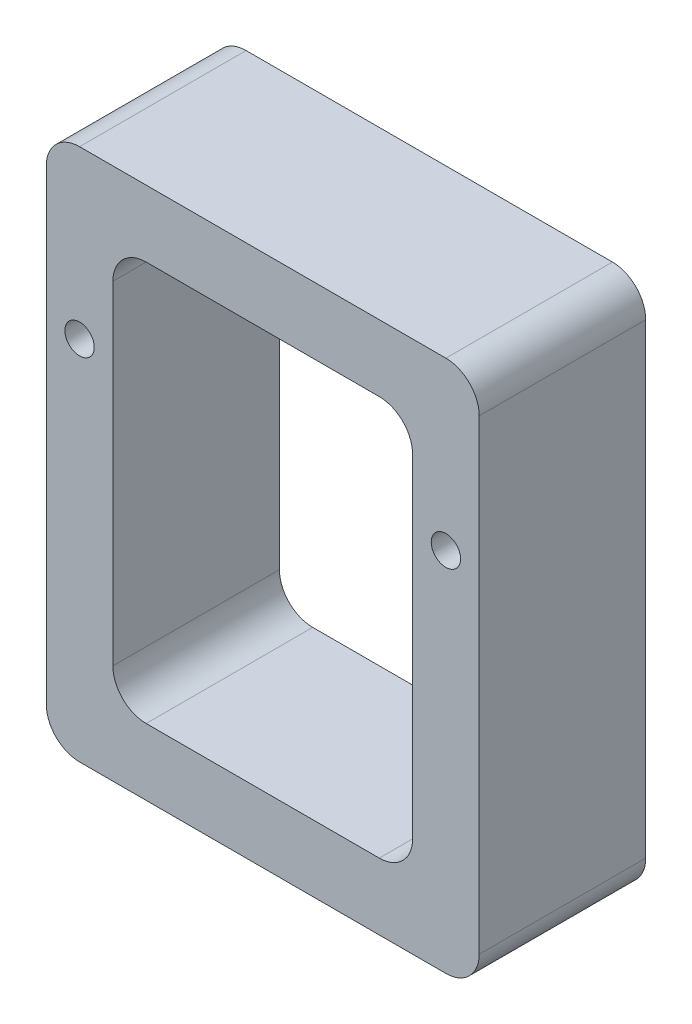
from build123d import *

# Parameters (mm, degrees)
SKETCH1_R           = 11.2
BOSS_EXTRUDE1_DEPTH = 127


with BuildPart() as part:
    # Sketch1 → Boss-Extrude1 (new body)
    with BuildSketch(Plane.XY):
        with BuildLine():
            Line((-139.7, -203.2), (139.7, -203.2))
            ThreePointArc((139.7, -203.2), (157.660512242, -195.760512242), (165.1, -177.8))
            Line((165.1, -177.8), (165.1, 177.8))
            ThreePointArc((165.1, 177.8), (157.660512242, 195.760512242), (139.7, 203.2))
            Line((139.7, 203.2), (-139.7, 203.2))
            ThreePointArc((-139.7, 203.2), (-157.660512242, 195.760512242), (-165.1, 177.8))
            Line((-165.1, 177.8), (-165.1, -177.8))
            ThreePointArc((-165.1, -177.8), (-157.660512242, -195.760512242), (-139.7, -203.2))
        make_face()
        with Locations((-139.7, 76.2)):
            Circle(SKETCH1_R, mode=Mode.SUBTRACT)
        with Locations((139.7, 76.2)):
            Circle(SKETCH1_R, mode=Mode.SUBTRACT)
        with BuildLine():
            Line((-114.3, -127), (-114.3, 127))
            ThreePointArc((-114.3, 127), (-106.860512242, 144.960512242), (-88.9, 152.4))
            Line((-88.9, 152.4), (88.9, 152.4))
            ThreePointArc((88.9, 152.4), (106.860512242, 144.960512242), (114.3, 127))
            Line((114.3, 127), (114.3, -127))
            ThreePointArc((114.3, -127), (106.860512242, -144.960512242), (88.9, -152.4))
            Line((88.9, -152.4), (-88.9, -152.4))
            ThreePointArc((-88.9, -152.4), (-106.860512242, -144.960512242), (-114.3, -127))
        make_face(mode=Mode.SUBTRACT)
    extrude(amount=BOSS_EXTRUDE1_DEPTH)


solid = part.part
